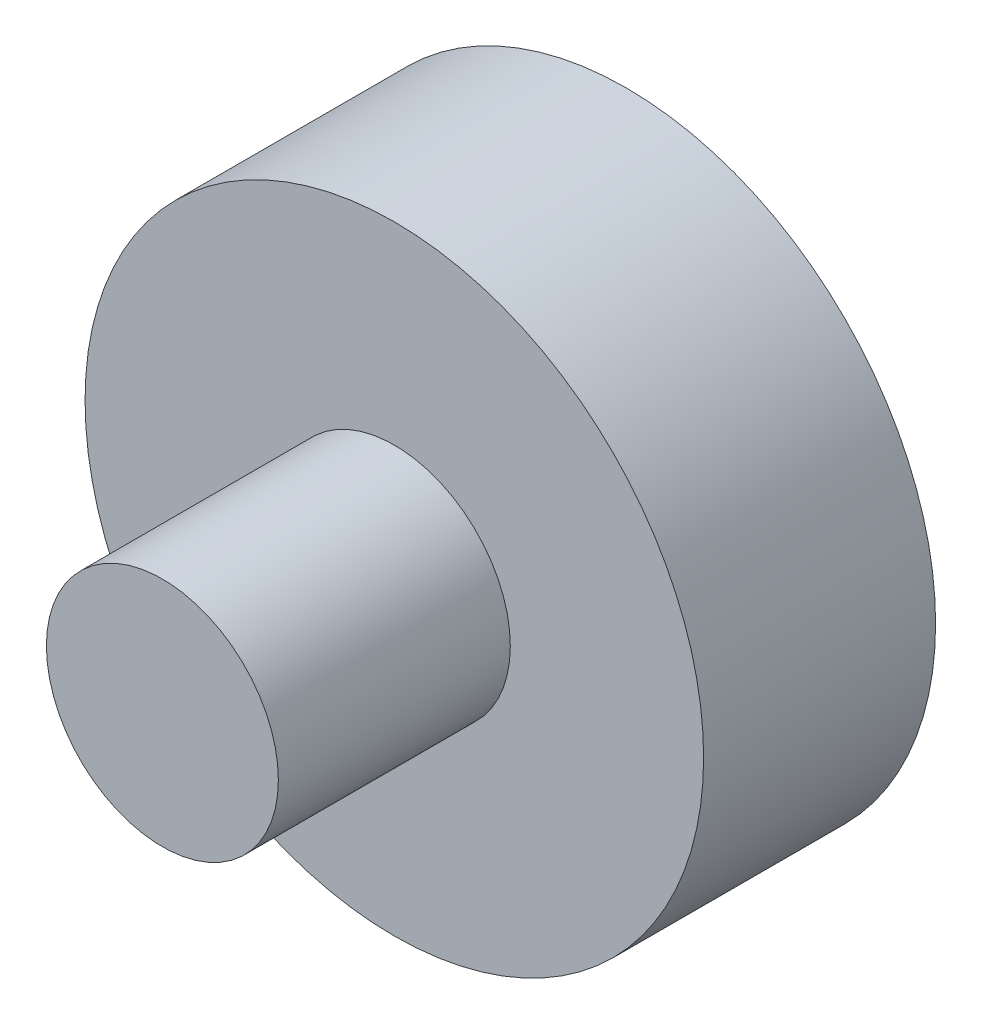
from build123d import *

# Parameters (mm, degrees)
SKETCH1_R           = 25.4
BOSS_EXTRUDE1_DEPTH = 19.05
SKETCH2_R           = 9.525
BOSS_EXTRUDE2_DEPTH = 19.05


with BuildPart() as part:
    # Sketch1 → Boss-Extrude1 (new body)
    with BuildSketch(Plane.XY):
        Circle(SKETCH1_R)
    extrude(amount=BOSS_EXTRUDE1_DEPTH)

    # Sketch2 → Boss-Extrude2 (add)
    with BuildSketch(Plane.XY.offset(19.05)):
        Circle(SKETCH2_R)
    extrude(amount=BOSS_EXTRUDE2_DEPTH)


solid = part.part
